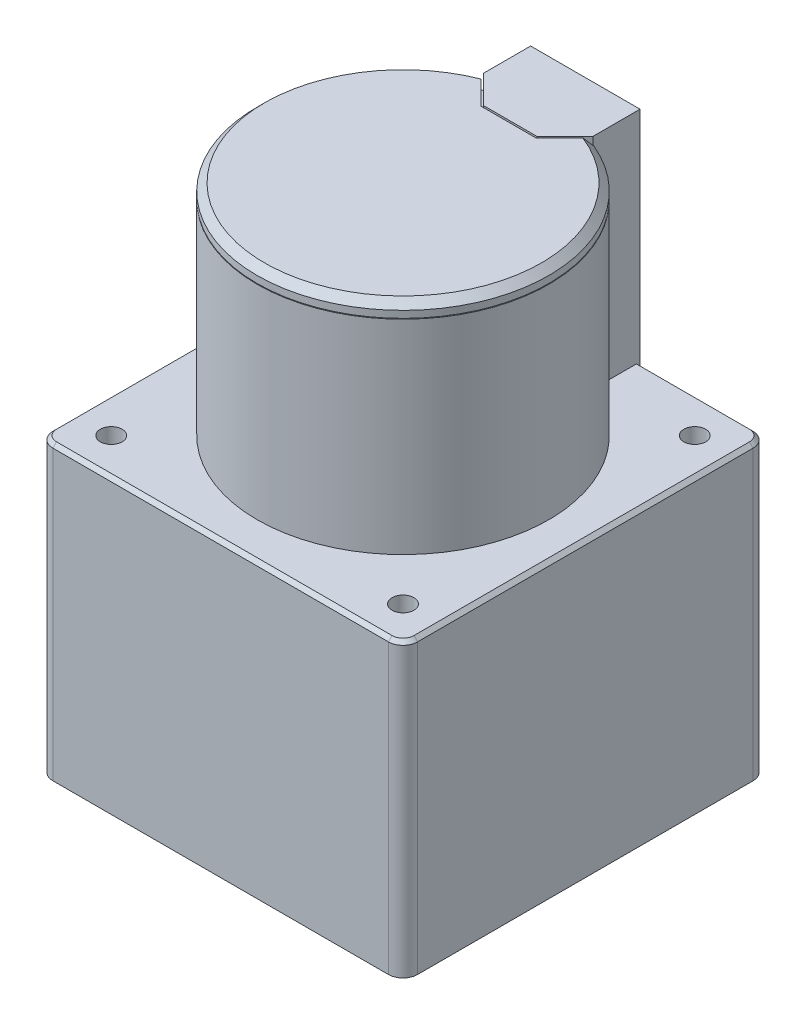
from build123d import *

# Parameters (mm, degrees)
SKETCH1_W           = 50
SKETCH1_H           = 50
SKETCH1_R           = 1.5
BOSS_EXTRUDE1_DEPTH = 40
BOSS_EXTRUDE2_DEPTH = 30
CUT_EXTRUDE1_DEPTH  = 0.05
CUT_EXTRUDE2_DEPTH  = 2.05
CHAMFER1_SIZE       = 1
FILLET1_R           = 2
CHAMFER3_SIZE       = 0.5


with BuildPart() as part:
    # Sketch1 → Boss-Extrude1 (new body)
    with BuildSketch(Plane(origin=(0, 0, 0), x_dir=(1, 0, 0), z_dir=(0, 1, 0))):
        with Locations((25, 25)):
            Rectangle(SKETCH1_W, SKETCH1_H)
        with Locations((5, 45)):
            Circle(SKETCH1_R, mode=Mode.SUBTRACT)
        with Locations((45, 45)):
            Circle(SKETCH1_R, mode=Mode.SUBTRACT)
        with Locations((5, 5)):
            Circle(SKETCH1_R, mode=Mode.SUBTRACT)
        with Locations((45, 5)):
            Circle(SKETCH1_R, mode=Mode.SUBTRACT)
    extrude(amount=BOSS_EXTRUDE1_DEPTH)

    # Sketch2 → Boss-Extrude2 (add)
    with BuildSketch(Plane(origin=(0, 40, 0), x_dir=(1, 0, 0), z_dir=(0, 1, 0))):
        with BuildLine():
            Line((17.5, 50), (32.5, 50))
            Line((32.5, 50), (32.5, 43.540496218))
            ThreePointArc((32.5, 43.540496218), (25, 5), (17.5, 43.540496218))
            Line((17.5, 43.540496218), (17.5, 50))
        make_face()
    extrude(amount=BOSS_EXTRUDE2_DEPTH)

    # Sketch3 → Cut-Extrude1 (cut, symmetric)
    with BuildSketch(Plane(origin=(0, 68, 0), x_dir=(1, 0, 0), z_dir=(0, 1, 0))):
        with BuildLine():
            Line((21, 39.70158955), (29, 39.70158955))
            Line((29, 39.70158955), (32.5, 43.540496218))
            Line((32.5, 43.540496218), (32.987378818, 44.151090821))
            ThreePointArc((32.987378818, 44.151090821), (25, 4.25), (17.012621182, 44.151090821))
            Line((17.012621182, 44.151090821), (17.5, 43.540496218))
            Line((17.5, 43.540496218), (21, 39.70158955))
        make_face()
        with BuildLine():
            Line((17.433019016, 43.242897215), (20.889622152, 39.45158955))
            Line((20.889622152, 39.45158955), (29.110377848, 39.45158955))
            Line((29.110377848, 39.45158955), (32.566980984, 43.242897215))
            ThreePointArc((32.566980984, 43.242897215), (25, 5.25), (17.433019016, 43.242897215))
        make_face(mode=Mode.SUBTRACT)
    extrude(amount=CUT_EXTRUDE1_DEPTH, both=True, mode=Mode.SUBTRACT)

    # Sketch4 → Cut-Extrude2 (cut)
    with BuildSketch(Plane(origin=(0, 70, 0), x_dir=(1, 0, 0), z_dir=(0, 1, 0))):
        Polygon((17.5, 43.540496218), (21.340496218, 39.7), (28.659503782, 39.7), (32.5, 43.540496218), (32.853553391, 43.540496218), (28.763057173, 39.45), (21.272298166, 39.45), (17.181801948, 43.540496218), align=None)
    extrude(amount=-CUT_EXTRUDE2_DEPTH, mode=Mode.SUBTRACT)

    # Chamfer1
    chamfer1_edges = [part.edges().sort_by_distance(p)[0] for p in [
        (24.986495471, 70, -5.000004559),
    ]]
    chamfer(chamfer1_edges, length=CHAMFER1_SIZE)

    # Fillet1
    fillet1_edges = [part.edges().sort_by_distance(p)[0] for p in [
        (0, 20, -50),
        (50, 20, -50),
        (50, 20, 0),
        (0, 20, 0),
    ]]
    fillet(fillet1_edges, radius=FILLET1_R)

    # Chamfer3
    chamfer3_edges = [part.edges().sort_by_distance(p)[0] for p in [
        (40.25, 40, -50),
        (50, 40, -25),
        (0, 40, -25),
        (25, 40, 0),
        (49.414213562, 40, -0.585786438),
        (0.585786438, 40, -0.585786438),
        (0.585786438, 40, -49.414213562),
        (49.414213562, 40, -49.414213562),
        (9.75, 40, -50),
    ]]
    chamfer(chamfer3_edges, length=CHAMFER3_SIZE)


solid = part.part
